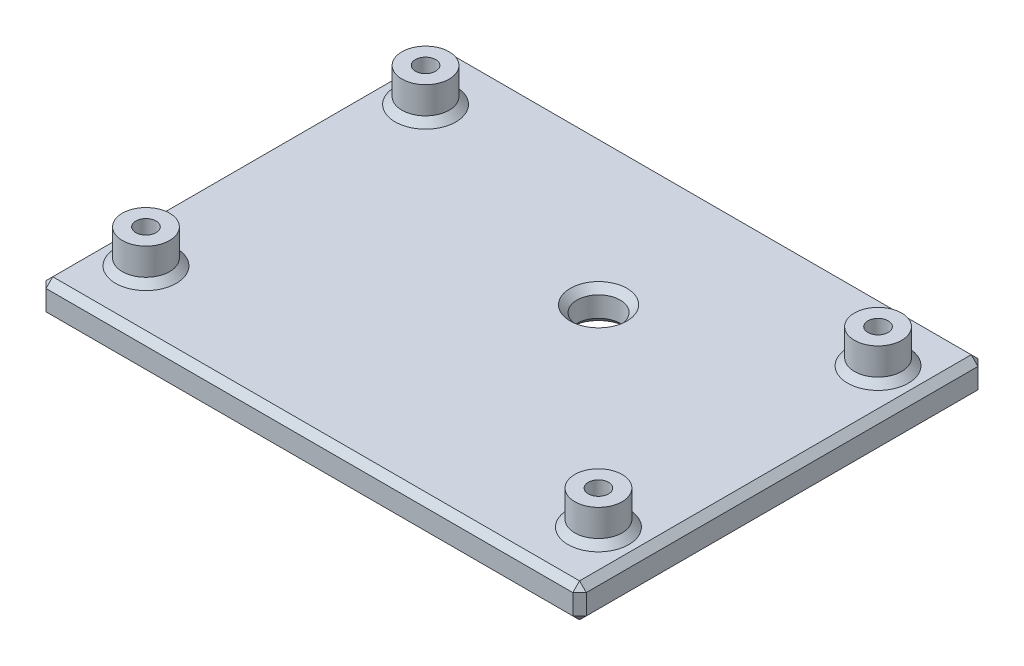
from build123d import *

# Parameters (mm, degrees)
SKETCH3_W           = 80
SKETCH3_H           = 60
BOSS_EXTRUDE1_DEPTH = 5
SKETCH5_R           = 3.5
BOSS_EXTRUDE2_DEPTH = 5
SKETCH6_R           = 1.5
SKETCH6_R_2         = 3.2
CUT_EXTRUDE1_DEPTH  = 11
CHAMFER1_SIZE       = 1


with BuildPart() as part:
    # Sketch3 → Boss-Extrude1 (new body)
    with BuildSketch(Plane(origin=(0, 0, 0), x_dir=(1, 0, 0), z_dir=(0, 1, 0))):
        Rectangle(SKETCH3_W, SKETCH3_H)
    extrude(amount=BOSS_EXTRUDE1_DEPTH)

    # Sketch5 → Boss-Extrude2 (add)
    with BuildSketch(Plane(origin=(0, 5, 0), x_dir=(1, 0, 0), z_dir=(0, 1, 0))):
        with Locations((33.5, 20.7)):
            Circle(SKETCH5_R)
        with Locations((33.5, -20.7)):
            Circle(SKETCH5_R)
        with Locations((-33.5, -20.7)):
            Circle(SKETCH5_R)
        with Locations((-33.5, 20.7)):
            Circle(SKETCH5_R)
    extrude(amount=BOSS_EXTRUDE2_DEPTH)

    # Sketch6 → Cut-Extrude1 (cut, through all)
    with BuildSketch(Plane(origin=(0, 0, 0), x_dir=(1, 0, 0), z_dir=(0, 1, 0))):
        with Locations((33.5, -20.7)):
            Circle(SKETCH6_R)
        with Locations((33.5, 20.7)):
            Circle(SKETCH6_R)
        with Locations((-33.5, -20.7)):
            Circle(SKETCH6_R)
        with Locations((-33.5, 20.7)):
            Circle(SKETCH6_R)
        with Locations((4.995, 7.825)):
            Circle(SKETCH6_R_2)
    extrude(amount=CUT_EXTRUDE1_DEPTH, mode=Mode.SUBTRACT)

    # Chamfer1
    chamfer1_edges = [part.edges().sort_by_distance(p)[0] for p in [
        (-40, 5, 0),
        (30, 5, -20.7),
        (0, 5, 30),
        (30, 5, 20.7),
        (-37, 5, 20.7),
        (-37, 5, -20.7),
        (32, 0, -20.7),
        (-35, 0, 20.7),
        (-35, 0, -20.7),
        (1.795, 0, -7.825),
        (1.795, 5, -7.825),
        (32, 0, 20.7),
        (40, 5, 0),
        (0, 0, 30),
        (-40, 0, 0),
        (0, 0, -30),
        (40, 0, 0),
        (40, 2.5, 30),
        (-40, 2.5, 30),
        (-40, 2.5, -30),
        (40, 2.5, -30),
        (0, 5, -30),
    ]]
    chamfer(chamfer1_edges, length=CHAMFER1_SIZE)


solid = part.part
